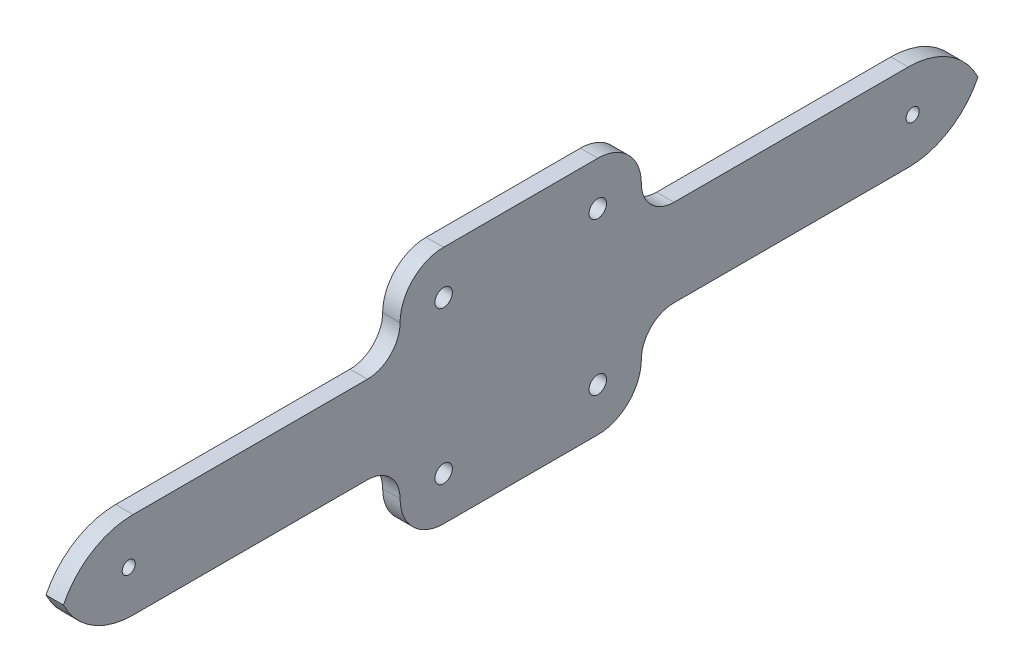
from build123d import *

# Parameters (mm, degrees)
SKETCH1_W               = 210
SKETCH1_H               = 61.270358306
BOSS_EXTRUDE1_DEPTH     = 4
SKETCH2_R               = 1.5
CUT_EXTRUDE1_DEPTH      = 5
SKETCH3_R               = 2
CUT_EXTRUDE2_DEPTH      = 5
CUT_EXTRUDE3_DEPTH      = 5
MIRROR3_COPY_1_SKETCH_R = 2
MIRROR3_COPY_1_DEPTH    = 5
MIRROR3_COPY_2_DEPTH    = 5


with BuildPart() as part:
    # Sketch1 → Boss-Extrude1 (new body)
    with BuildSketch(Plane(origin=(0, 0, 0), x_dir=(0, 0, -1), z_dir=(1, 0, 0))):
        Rectangle(SKETCH1_W, SKETCH1_H)
    extrude(amount=BOSS_EXTRUDE1_DEPTH)

    # Sketch2 → Cut-Extrude1 (cut, through all)
    with BuildSketch(Plane(origin=(4, 0, 0), x_dir=(0, 0, -1), z_dir=(1, 0, 0))):
        with Locations((-90, 0)):
            Circle(SKETCH2_R)
    cut_extrude1 = extrude(amount=-CUT_EXTRUDE1_DEPTH, mode=Mode.SUBTRACT)

    # Sketch3 → Cut-Extrude2 (cut, through all)
    with BuildSketch(Plane(origin=(4, 0, 0), x_dir=(0, 0, -1), z_dir=(1, 0, 0))):
        with Locations((-17.7, 17.5)):
            Circle(SKETCH3_R)
    cut_extrude2 = extrude(amount=-CUT_EXTRUDE2_DEPTH, mode=Mode.SUBTRACT)

    # Sketch4 → Cut-Extrude3 (cut, through all)
    with BuildSketch(Plane(origin=(4, 0, 0), x_dir=(0, 0, -1), z_dir=(1, 0, 0))):
        with BuildLine():
            Line((-89, 10), (-35.2, 10))
            ThreePointArc((-35.2, 10), (-29.896699141, 12.196699141), (-27.7, 17.5))
            ThreePointArc((-27.7, 17.5), (-24.771067812, 24.571067812), (-17.7, 27.5))
            Line((-17.7, 27.5), (0, 27.5))
            Line((0, 27.5), (0, 30.635179153))
            Line((0, 30.635179153), (-105, 30.635179153))
            Line((-105, 30.635179153), (-105, 0))
            ThreePointArc((-105, 0), (-98.433981132, 7.294369811), (-89, 10))
        make_face()
    cut_extrude3 = extrude(amount=-CUT_EXTRUDE3_DEPTH, mode=Mode.SUBTRACT)

    # Mirror2: Cut-Extrude2, Cut-Extrude3 across plane
    add(cut_extrude2.mirror(Plane.ZX), mode=Mode.SUBTRACT)
    add(cut_extrude3.mirror(Plane.ZX), mode=Mode.SUBTRACT)

    # Mirror3: Cut-Extrude3, Cut-Extrude1, Cut-Extrude2 across plane
    add(cut_extrude3.mirror(Plane.XY), mode=Mode.SUBTRACT)
    add(cut_extrude1.mirror(Plane.XY), mode=Mode.SUBTRACT)
    add(cut_extrude2.mirror(Plane.XY), mode=Mode.SUBTRACT)

    # Mirror3 copy 1 sketch → Mirror3 copy 1 (cut, through all)
    with BuildSketch(Plane(origin=(4, 0, 0), x_dir=(0, 0, 1), z_dir=(1, 0, 0))):
        with Locations((-17.7, 17.5)):
            Circle(MIRROR3_COPY_1_SKETCH_R)
    extrude(amount=-MIRROR3_COPY_1_DEPTH, mode=Mode.SUBTRACT)

    # Mirror3 copy 2 sketch → Mirror3 copy 2 (cut, through all)
    with BuildSketch(Plane(origin=(4, 0, 0), x_dir=(0, 0, 1), z_dir=(1, 0, 0))):
        with BuildLine():
            Line((-89, 10), (-35.2, 10))
            ThreePointArc((-35.2, 10), (-29.896699141, 12.196699141), (-27.7, 17.5))
            ThreePointArc((-27.7, 17.5), (-24.771067812, 24.571067812), (-17.7, 27.5))
            Line((-17.7, 27.5), (0, 27.5))
            Line((0, 27.5), (0, 30.635179153))
            Line((0, 30.635179153), (-105, 30.635179153))
            Line((-105, 30.635179153), (-105, 0))
            ThreePointArc((-105, 0), (-98.433981132, 7.294369811), (-89, 10))
        make_face()
    extrude(amount=-MIRROR3_COPY_2_DEPTH, mode=Mode.SUBTRACT)


solid = part.part
